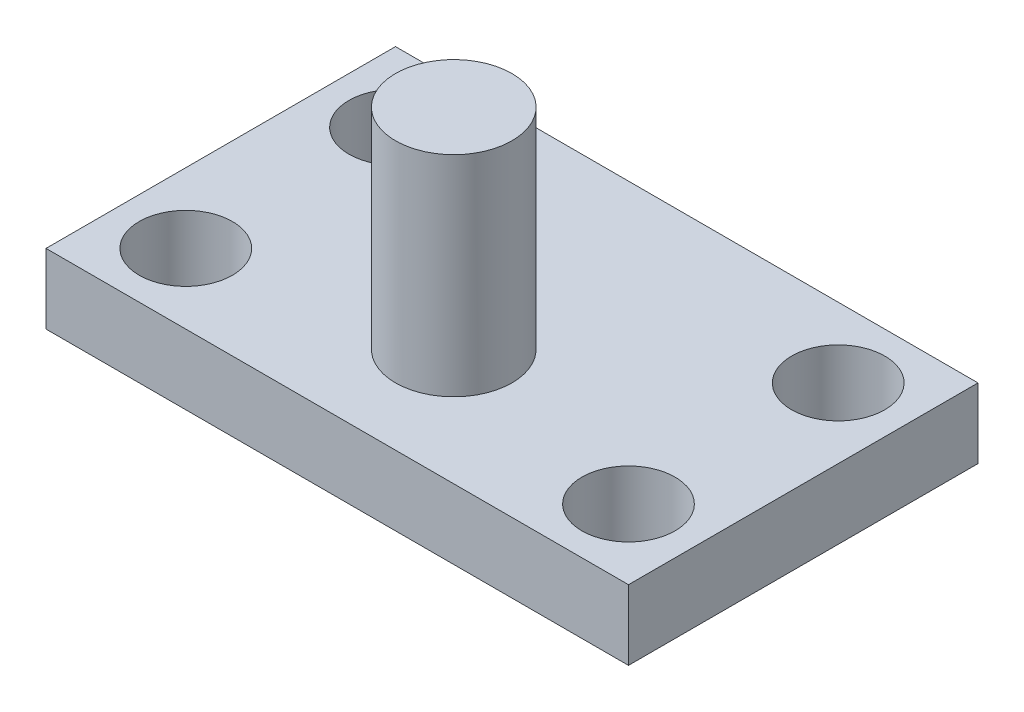
from build123d import *

# Parameters (mm, degrees)
SKETCH1_W                = 250
SKETCH1_H                = 150
SKETCH1_R                = 20
SKETCH1_R_2              = 25
BOSS_EXTRUDE1_DEPTH      = 15
SKETCH2_R                = 25
BOSS_EXTRUDE2_DEPTH      = 2
BOSS_EXTRUDE2_DEPTH_BACK = 120
SKETCH3_R                = 25
CUT_EXTRUDE1_DEPTH       = 2


with BuildPart() as part:
    # Sketch1 → Boss-Extrude1 (new body, symmetric)
    with BuildSketch(Plane(origin=(0, 0, 0), x_dir=(1, 0, 0), z_dir=(0, 1, 0))):
        with Locations((38.481860276, -16.453513268)):
            Rectangle(SKETCH1_W, SKETCH1_H)
        with Locations((-56.518139724, 28.546486732)):
            Circle(SKETCH1_R, mode=Mode.SUBTRACT)
        with Locations((133.481860276, 28.546486732)):
            Circle(SKETCH1_R, mode=Mode.SUBTRACT)
        with Locations((133.481860276, -61.453513268)):
            Circle(SKETCH1_R, mode=Mode.SUBTRACT)
        with Locations((-56.518139724, -61.453513268)):
            Circle(SKETCH1_R, mode=Mode.SUBTRACT)
        with Locations((38.481860276, -41.453513268)):
            Circle(SKETCH1_R_2, mode=Mode.SUBTRACT)
    extrude(amount=BOSS_EXTRUDE1_DEPTH, both=True)

    # Sketch2 → Boss-Extrude2 (add, two sides)
    with BuildSketch(Plane.XZ.offset(15)) as boss_extrude2_sk:
        with Locations((38.481860276, 41.453513268)):
            Circle(SKETCH2_R)
    extrude(amount=BOSS_EXTRUDE2_DEPTH)
    extrude(boss_extrude2_sk.sketch, amount=-BOSS_EXTRUDE2_DEPTH_BACK)

    # Sketch3 → Cut-Extrude1 (cut)
    with BuildSketch(Plane(origin=(0, -17, 0), x_dir=(-1, 0, 0), z_dir=(0, -1, 0))):
        with Locations((-38.481860276, -41.453513268)):
            Circle(SKETCH3_R)
    extrude(amount=-CUT_EXTRUDE1_DEPTH, mode=Mode.SUBTRACT)


solid = part.part
